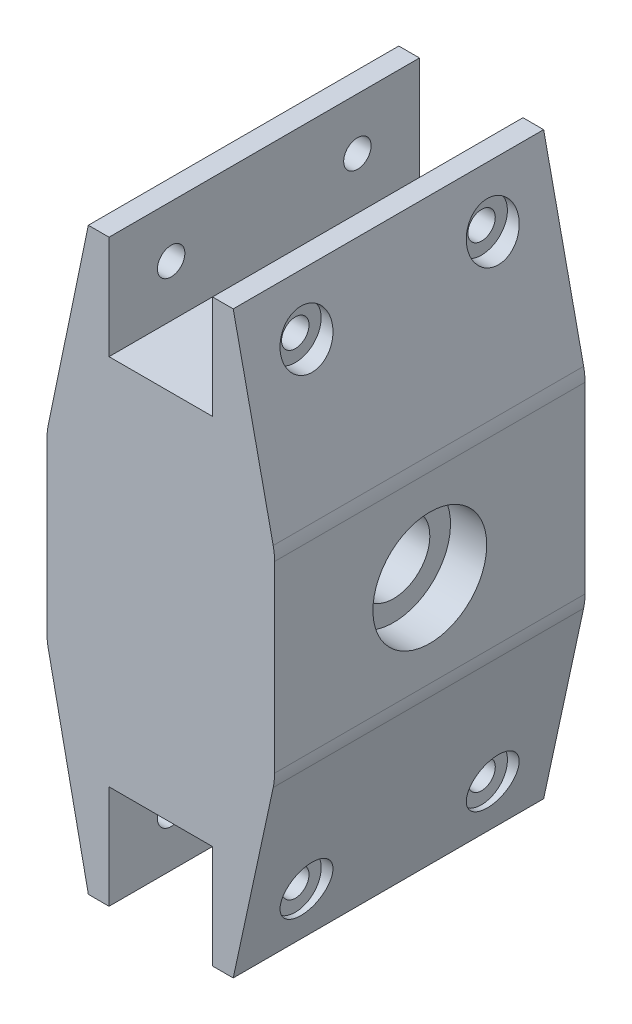
from build123d import *

# Parameters (mm, degrees)
SKETCH1_W           = 20
SKETCH1_H           = 72
BOSS_EXTRUDE1_DEPTH = 60
SKETCH2_R           = 7
CUT_EXTRUDE1_DEPTH  = 45
SKETCH3_R           = 11
CUT_EXTRUDE2_DEPTH  = 7
SKETCH4_R           = 11
CUT_EXTRUDE3_DEPTH  = 7
SKETCH5_R           = 2.65
CUT_EXTRUDE4_DEPTH  = 41
SKETCH6_R           = 5
CUT_EXTRUDE5_DEPTH  = 4
FILLET1_R           = 12
SKETCH7_R           = 5
CUT_EXTRUDE6_DEPTH  = 4


with BuildPart() as part:
    # Sketch1 → Boss-Extrude1 (new body)
    with BuildSketch(Plane.XY):
        Polygon((10, 36), (10, 56), (14, 56), (22, 19), (22, -19), (14, -56), (10, -56), (10, -36), align=None)
        Rectangle(SKETCH1_W, SKETCH1_H)
        Polygon((-14, -56), (-10, -56), (-10, -36), (-10, 36), (-10, 56), (-14, 56), (-22, 17.5), (-22, -17.5), align=None)
        Polygon((14, 56), (22, 19), (22, -19), (14, -56), align=None)
    extrude(amount=BOSS_EXTRUDE1_DEPTH)

    # Sketch2 → Cut-Extrude1 (cut, through all)
    with BuildSketch(Plane.ZY.offset(22)):
        with Locations((30, 0)):
            Circle(SKETCH2_R)
    extrude(amount=-CUT_EXTRUDE1_DEPTH, mode=Mode.SUBTRACT)

    # Sketch3 → Cut-Extrude2 (cut)
    with BuildSketch(Plane.ZY.offset(22)):
        with Locations((30, 0)):
            Circle(SKETCH3_R)
    extrude(amount=-CUT_EXTRUDE2_DEPTH, mode=Mode.SUBTRACT)

    # Sketch4 → Cut-Extrude3 (cut)
    with BuildSketch(Plane(origin=(22, 0, 0), x_dir=(0, 0, -1), z_dir=(1, 0, 0))):
        with Locations((-30, 0)):
            Circle(SKETCH4_R)
    extrude(amount=-CUT_EXTRUDE3_DEPTH, mode=Mode.SUBTRACT)

    # Sketch5 → Cut-Extrude4 (cut, through all)
    with BuildSketch(Plane(origin=(-18, 0, 0), x_dir=(0, 0, -1), z_dir=(1, 0, 0))):
        with Locations((-12, 46)):
            Circle(SKETCH5_R)
        with Locations((-48, 46)):
            Circle(SKETCH5_R)
    cut_extrude4 = extrude(amount=CUT_EXTRUDE4_DEPTH, mode=Mode.SUBTRACT)

    # Sketch6 → Cut-Extrude5 (cut)
    with BuildSketch(Plane(origin=(-18, 0, 0), x_dir=(0, 0, -1), z_dir=(1, 0, 0))):
        with Locations((-12, 46)):
            Circle(SKETCH6_R)
        with Locations((-48, 46)):
            Circle(SKETCH6_R)
    cut_extrude5 = extrude(amount=CUT_EXTRUDE5_DEPTH, mode=Mode.SUBTRACT)

    # Mirror3: Cut-Extrude4, Cut-Extrude5 across plane
    add(cut_extrude4.mirror(Plane.ZX), mode=Mode.SUBTRACT)
    add(cut_extrude5.mirror(Plane.ZX), mode=Mode.SUBTRACT)

    # Fillet1
    fillet1_edges = [part.edges().sort_by_distance(p)[0] for p in [
        (-22, -17.5, 30),
        (-22, 17.5, 30),
        (22, 19, 30),
        (22, -19, 30),
    ]]
    fillet(fillet1_edges, radius=FILLET1_R)

    # Sketch7 → Cut-Extrude6 (cut)
    with BuildSketch(Plane.ZY.offset(-18)):
        with Locations((12, 46)):
            Circle(SKETCH7_R)
        with Locations((48, 46)):
            Circle(SKETCH7_R)
    cut_extrude6 = extrude(amount=CUT_EXTRUDE6_DEPTH, mode=Mode.SUBTRACT)

    # Mirror5: Cut-Extrude6 across plane
    add(cut_extrude6.mirror(Plane.ZX), mode=Mode.SUBTRACT)


solid = part.part
